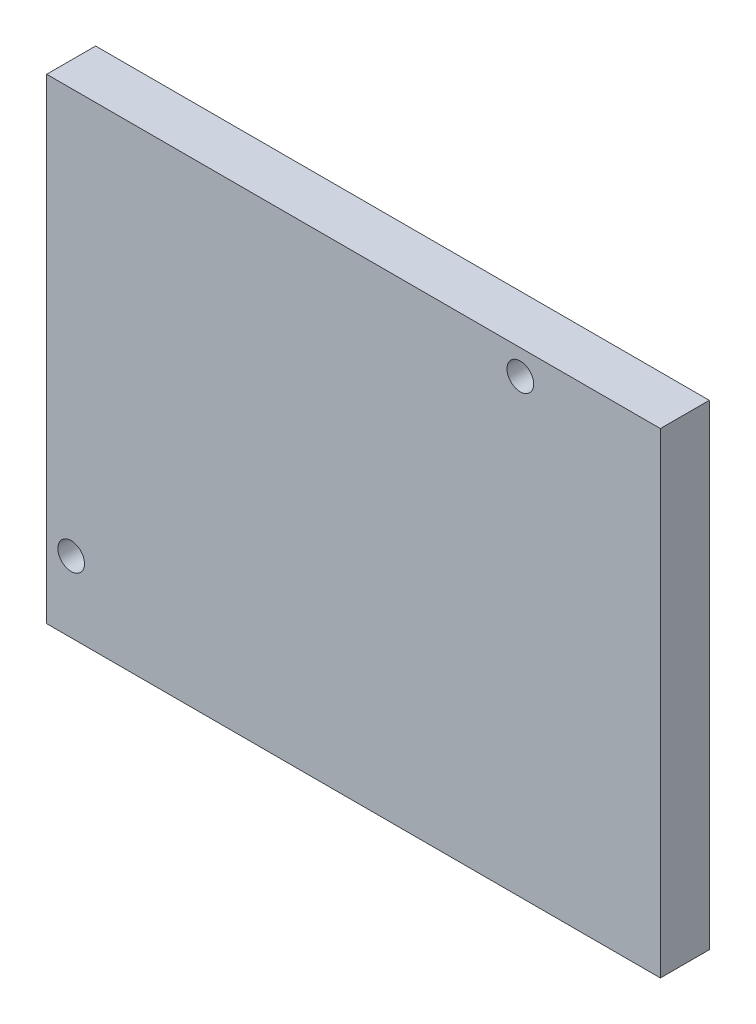
from build123d import *

# Parameters (mm, degrees)
SKETCH1_W           = 69
SKETCH1_H           = 53.5
SKETCH1_R           = 1.5
BOSS_EXTRUDE1_DEPTH = 5.5


with BuildPart() as part:
    # Sketch1 → Boss-Extrude1 (new body)
    with BuildSketch(Plane.XY):
        Rectangle(SKETCH1_W, SKETCH1_H)
        with Locations((18.75, 23.95)):
            Circle(SKETCH1_R, mode=Mode.SUBTRACT)
        with Locations((-31.75, -18.79)):
            Circle(SKETCH1_R, mode=Mode.SUBTRACT)
    extrude(amount=BOSS_EXTRUDE1_DEPTH)


solid = part.part
